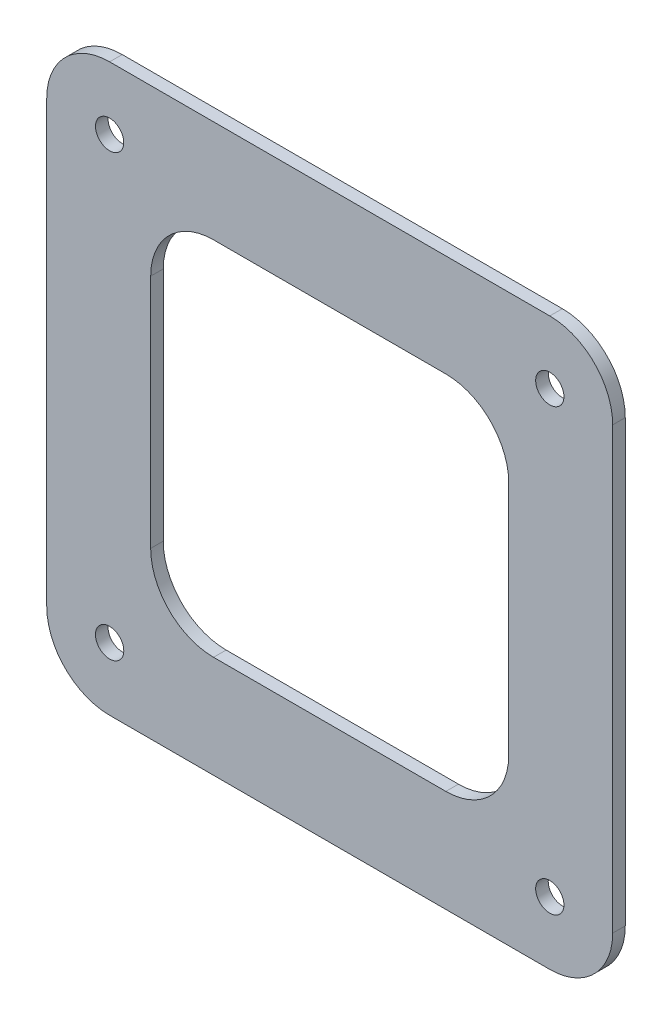
from build123d import *

# Parameters (mm, degrees)
BOSS_EXTRU_1_DEPTH      = 2
ESQUISSE2_R             = 2.25
ENL_V_MAT_EXTRU_1_DEPTH = 3
ENL_V_MAT_EXTRU_2_DEPTH = 10


with BuildPart() as part:
    # Esquisse1 → Boss.-Extru.1 (new body)
    with BuildSketch(Plane.XY):
        with BuildLine():
            Line((35, -45), (-35, -45))
            ThreePointArc((-35, -45), (-42.071067812, -42.071067812), (-45, -35))
            Line((-45, -35), (-45, 35))
            ThreePointArc((-45, 35), (-42.071067812, 42.071067812), (-35, 45))
            Line((-35, 45), (35, 45))
            ThreePointArc((35, 45), (42.071067812, 42.071067812), (45, 35))
            Line((45, 35), (45, -35))
            ThreePointArc((45, -35), (42.071067812, -42.071067812), (35, -45))
        make_face()
    extrude(amount=BOSS_EXTRU_1_DEPTH)

    # Esquisse2 → Enlèv. mat.-Extru.1 (cut, through all)
    with BuildSketch(Plane(origin=(0, 0, 0), x_dir=(-1, 0, 0), z_dir=(0, 0, -1))):
        with Locations((-35, -35)):
            Circle(ESQUISSE2_R)
        with Locations((-35, 35)):
            Circle(ESQUISSE2_R)
        with Locations((35, -35)):
            Circle(ESQUISSE2_R)
        with Locations((35, 35)):
            Circle(ESQUISSE2_R)
    extrude(amount=-ENL_V_MAT_EXTRU_1_DEPTH, mode=Mode.SUBTRACT)

    # Esquisse4 → Enlèv. mat.-Extru.2 (cut)
    with BuildSketch(Plane(origin=(0, 0, 0), x_dir=(-1, 0, 0), z_dir=(0, 0, -1))):
        with BuildLine():
            Line((-18.471463814, -28.745227889), (18.471463814, -28.745227889))
            ThreePointArc((18.471463814, -28.745227889), (25.542531626, -25.816295701), (28.471463814, -18.745227889))
            Line((28.471463814, -18.745227889), (28.471463814, 18.745227889))
            ThreePointArc((28.471463814, 18.745227889), (25.542531626, 25.816295701), (18.471463814, 28.745227889))
            Line((18.471463814, 28.745227889), (-18.471463814, 28.745227889))
            ThreePointArc((-18.471463814, 28.745227889), (-25.542531626, 25.816295701), (-28.471463814, 18.745227889))
            Line((-28.471463814, 18.745227889), (-28.471463814, -18.745227889))
            ThreePointArc((-28.471463814, -18.745227889), (-25.542531626, -25.816295701), (-18.471463814, -28.745227889))
        make_face()
    extrude(amount=-ENL_V_MAT_EXTRU_2_DEPTH, mode=Mode.SUBTRACT)


solid = part.part
